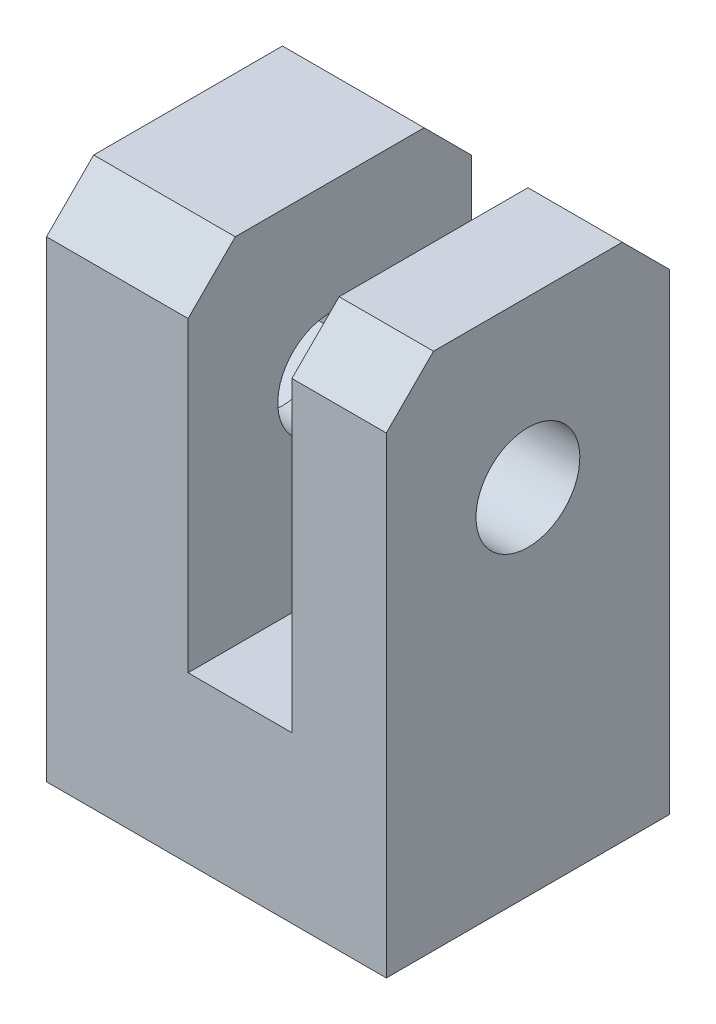
from build123d import *

# Parameters (mm, degrees)
BOSS_EXTRUDE1_DEPTH = 6
CUT_EXTRUDE1_REACH  = 4
SKETCH2_R           = 1.1
CUT_EXTRUDE2_REACH  = 3
SKETCH3_R           = 1.1
SKETCH5_W           = 6
SKETCH5_H           = 11
BOSS_EXTRUDE2_DEPTH = 2
CUT_EXTRUDE3_REACH  = 13
SKETCH4_R           = 0.95
CHAMFER1_SIZE       = 1


with BuildPart() as part:
    # Sketch1 → Boss-Extrude1 (new body)
    with BuildSketch(Plane.XY):
        Polygon((-1.1, 7.5), (-1.1, 0), (1.1, 0), (1.1, 7.5), (3.1, 7.5), (3.1, -3.5), (-2.1, -3.5), (-2.1, 7.5), align=None)
    extrude(amount=BOSS_EXTRUDE1_DEPTH)

    # Sketch2 → Cut-Extrude1 (cut, up to next)
    with BuildSketch(Plane.ZY.offset(-1.1), mode=Mode.PRIVATE) as cut_extrude1_sk1:
        with Locations((3, 4)):
            Circle(SKETCH2_R)
    cut_extrude1_tool1 = extrude(cut_extrude1_sk1.sketch, amount=-CUT_EXTRUDE1_REACH, mode=Mode.PRIVATE) & part.part
    add(cut_extrude1_tool1.solids().sort_by_distance((1.1, 4, 3))[0], mode=Mode.SUBTRACT)

    # Sketch3 → Cut-Extrude2 (cut, up to next)
    with BuildSketch(Plane(origin=(-1.1, 0, 0), x_dir=(0, 0, -1), z_dir=(1, 0, 0)), mode=Mode.PRIVATE) as cut_extrude2_sk1:
        with Locations((-3, 4)):
            Circle(SKETCH3_R)
    cut_extrude2_tool1 = extrude(cut_extrude2_sk1.sketch, amount=-CUT_EXTRUDE2_REACH, mode=Mode.PRIVATE) & part.part
    add(cut_extrude2_tool1.solids().sort_by_distance((-1.1, 4, 3))[0], mode=Mode.SUBTRACT)

    # Sketch5 → Boss-Extrude2 (add)
    with BuildSketch(Plane.ZY.offset(2.1)):
        with Locations((3, 2)):
            Rectangle(SKETCH5_W, SKETCH5_H)
        Polygon((5, 2.845299462), (5, 5.154700538), (3, 6.309401077), (1, 5.154700538), (1, 2.845299462), (3, 1.690598923), align=None, mode=Mode.SUBTRACT)
    extrude(amount=BOSS_EXTRUDE2_DEPTH)

    # Sketch4 → Cut-Extrude3 (cut, up to next)
    with BuildSketch(Plane.XZ.offset(3.5), mode=Mode.PRIVATE) as cut_extrude3_sk1:
        with Locations((0, 3)):
            Circle(SKETCH4_R)
    cut_extrude3_tool1 = extrude(cut_extrude3_sk1.sketch, amount=-CUT_EXTRUDE3_REACH, mode=Mode.PRIVATE) & part.part
    add(cut_extrude3_tool1.solids().sort_by_distance((0, -3.5, 3))[0], mode=Mode.SUBTRACT)

    # Chamfer1
    chamfer1_edges = [part.edges().sort_by_distance(p)[0] for p in [
        (2.1, 7.5, 0),
        (-2.6, 7.5, 6),
        (2.1, 7.5, 6),
        (-2.6, 7.5, 0),
    ]]
    chamfer(chamfer1_edges, length=CHAMFER1_SIZE)


solid = part.part
